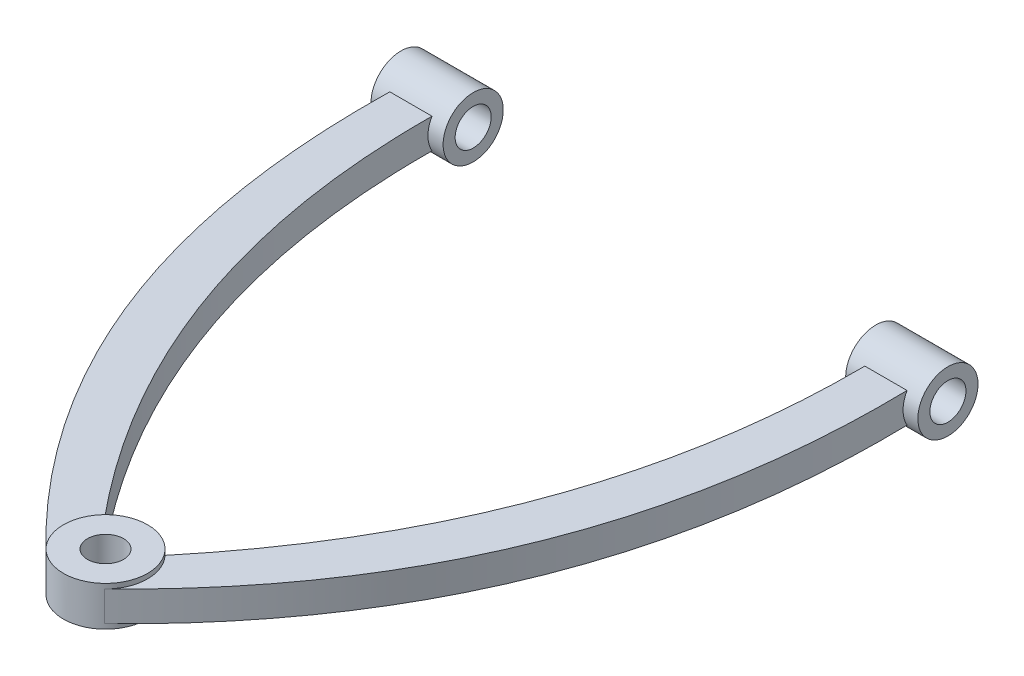
from build123d import *

# Parameters (mm, degrees)
CROQUIS1_R              = 7.5
SALIENTE_EXTRUIR1_DEPTH = 12.5
CROQUIS3_R              = 12.5
CROQUIS3_R_2            = 7.5
SALIENTE_EXTRUIR2_DEPTH = 15
CROQUIS4_R              = 17.5
CROQUIS4_R_2            = 7.5
SALIENTE_EXTRUIR3_DEPTH = 2
CROQUIS5_R              = 17.5
CROQUIS5_R_2            = 7.5
SALIENTE_EXTRUIR4_DEPTH = 2


with BuildPart() as part:
    # Croquis1 → Saliente-Extruir1 (new body)
    with BuildSketch(Plane(origin=(0, 0, 0), x_dir=(1, 0, 0), z_dir=(0, 1, 0))):
        with BuildLine():
            Line((-107.423550962, 229), (-89.923550962, 229))
            add(Edge.make_bspline(
                [(-89.923550962, 229), (-92.027233401, 107.676295976), (-12.647886898, 12.09466647)],
                knots=[0, 0, 0, 1, 1, 1], degree=2))
            ThreePointArc((-12.647886898, 12.09466647), (0, 17.5), (12.647886898, 12.09466647))
            add(Edge.make_bspline(
                [(89.923550962, 229), (92.027233401, 107.676295976), (12.647886898, 12.09466647)],
                knots=[0, 0, 0, 1, 1, 1], degree=2))
            Line((89.923550962, 229), (107.423550962, 229))
            add(Edge.make_bspline(
                [(107.423550962, 229), (111.604135582, 83.182199319), (12.139143835, -12.605204756)],
                knots=[0, 0, 0, 1, 1, 1], degree=2))
            ThreePointArc((12.139143835, -12.605204756), (0, -17.5), (-12.139143835, -12.605204756))
            add(Edge.make_bspline(
                [(-107.423550962, 229), (-111.604135582, 83.182199319), (-12.139143835, -12.605204756)],
                knots=[0, 0, 0, 1, 1, 1], degree=2))
        make_face()
        Circle(CROQUIS1_R, mode=Mode.SUBTRACT)
    extrude(amount=SALIENTE_EXTRUIR1_DEPTH)

    # Croquis3 → Saliente-Extruir2 (add, symmetric)
    with BuildSketch(Plane(origin=(98.673550962, 0, 0), x_dir=(0, 0, -1), z_dir=(1, 0, 0))):
        with Locations((236.5, 6.25)):
            Circle(CROQUIS3_R)
        with Locations((236.5, 6.25)):
            Circle(CROQUIS3_R_2, mode=Mode.SUBTRACT)
    saliente_extruir2 = extrude(amount=SALIENTE_EXTRUIR2_DEPTH, both=True)

    # Simetría1: Saliente-Extruir2 across plane
    add(saliente_extruir2.mirror(Plane(origin=(0, 0, 0), x_dir=(0, 0, 1), z_dir=(1, 0, 0))))

    # Croquis4 → Saliente-Extruir3 (add)
    with BuildSketch(Plane(origin=(0, 12.5, 0), x_dir=(1, 0, 0), z_dir=(0, 1, 0))):
        Circle(CROQUIS4_R)
        Circle(CROQUIS4_R_2, mode=Mode.SUBTRACT)
    extrude(amount=SALIENTE_EXTRUIR3_DEPTH)

    # Croquis5 → Saliente-Extruir4 (add)
    with BuildSketch(Plane.XZ):
        Circle(CROQUIS5_R)
        Circle(CROQUIS5_R_2, mode=Mode.SUBTRACT)
    extrude(amount=SALIENTE_EXTRUIR4_DEPTH)


solid = part.part
